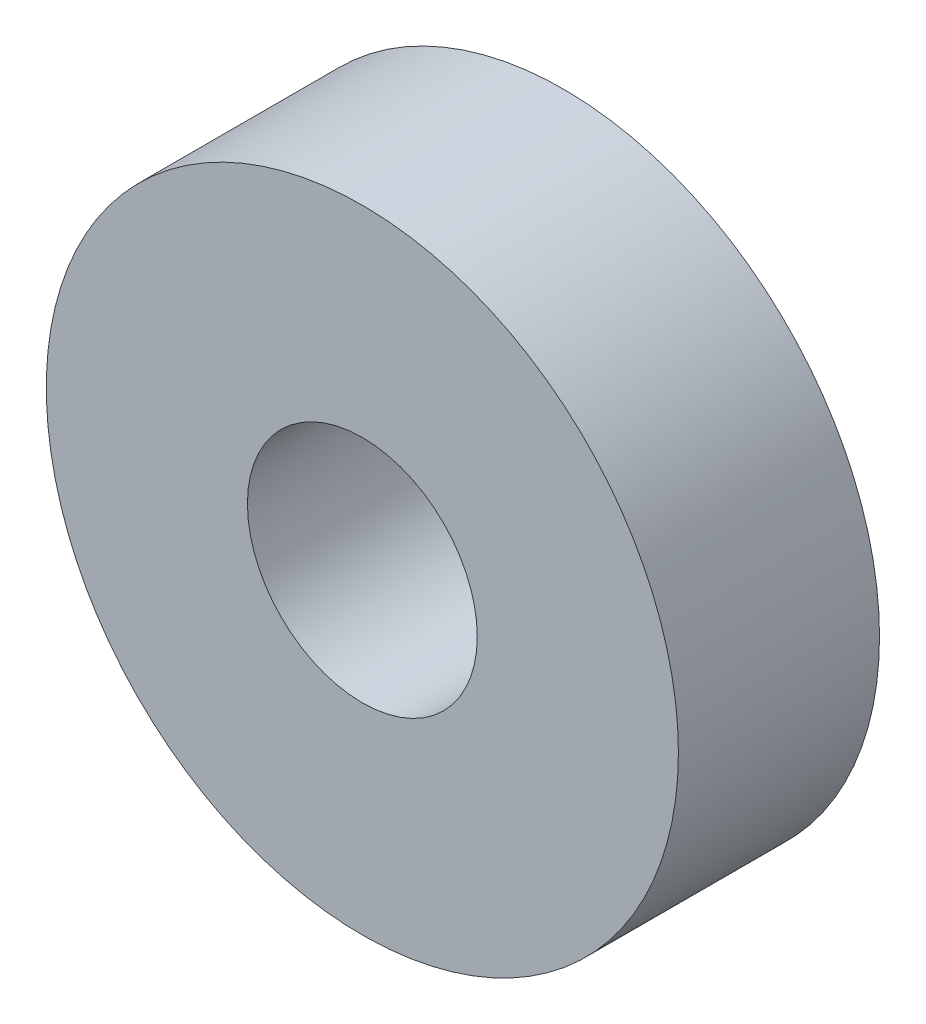
from build123d import *

# Parameters (mm, degrees)
ESQUISSE1_R        = 11
ESQUISSE1_R_2      = 4
BOSS_EXTRU_1_DEPTH = 7


with BuildPart() as part:
    # Esquisse1 → Boss.-Extru.1 (new body)
    with BuildSketch(Plane.XY):
        Circle(ESQUISSE1_R)
        Circle(ESQUISSE1_R_2, mode=Mode.SUBTRACT)
    extrude(amount=BOSS_EXTRU_1_DEPTH)


solid = part.part
